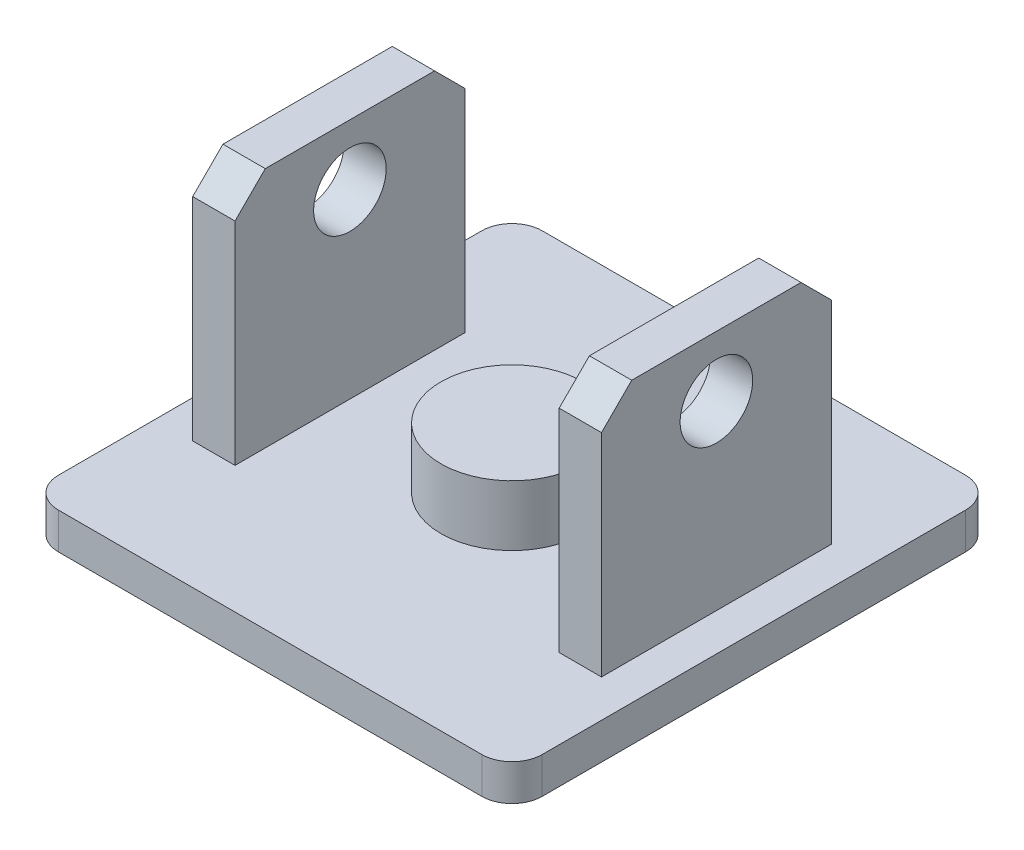
from build123d import *

# Parameters (mm, degrees)
SKETCH1_W           = 40
SKETCH1_H           = 40
BOSS_EXTRUDE1_DEPTH = 3
SKETCH2_R           = 5.875
BOSS_EXTRUDE2_DEPTH = 5
SKETCH3_W           = 3.5
SKETCH3_H           = 19
BOSS_EXTRUDE3_DEPTH = 20
SKETCH4_R           = 3
CUT_EXTRUDE1_DEPTH  = 3.5
FILLET1_R           = 2.5
CHAMFER1_SIZE       = 2.5


with BuildPart() as part:
    # Sketch1 → Boss-Extrude1 (new body)
    with BuildSketch(Plane(origin=(0, 0, 0), x_dir=(1, 0, 0), z_dir=(0, 1, 0))):
        Rectangle(SKETCH1_W, SKETCH1_H)
    extrude(amount=BOSS_EXTRUDE1_DEPTH)

    # Sketch2 → Boss-Extrude2 (add)
    with BuildSketch(Plane(origin=(0, 3, 0), x_dir=(1, 0, 0), z_dir=(0, 1, 0))):
        Circle(SKETCH2_R)
    extrude(amount=BOSS_EXTRUDE2_DEPTH)

    # Sketch3 → Boss-Extrude3 (add)
    with BuildSketch(Plane(origin=(0, 3, 0), x_dir=(1, 0, 0), z_dir=(0, 1, 0))):
        with Locations((15.15, 0)):
            Rectangle(SKETCH3_W, SKETCH3_H)
    boss_extrude3 = extrude(amount=BOSS_EXTRUDE3_DEPTH)

    # Sketch4 → Cut-Extrude1 (cut)
    with BuildSketch(Plane(origin=(16.9, 0, 0), x_dir=(0, 0, -1), z_dir=(1, 0, 0))):
        with Locations((0, 18)):
            Circle(SKETCH4_R)
    cut_extrude1 = extrude(amount=-CUT_EXTRUDE1_DEPTH, mode=Mode.SUBTRACT)

    # Fillet1
    fillet1_edges = [part.edges().sort_by_distance(p)[0] for p in [
        (20, 1.5, 20),
        (-20, 1.5, 20),
        (-20, 1.5, -20),
        (20, 1.5, -20),
    ]]
    fillet(fillet1_edges, radius=FILLET1_R)

    # Mirror1: Boss-Extrude3, Cut-Extrude1 across plane
    add(boss_extrude3.mirror(Plane(origin=(0, 0, 0), x_dir=(0, 0, 1), z_dir=(1, 0, 0))))
    add(cut_extrude1.mirror(Plane(origin=(0, 0, 0), x_dir=(0, 0, 1), z_dir=(1, 0, 0))), mode=Mode.SUBTRACT)

    # Chamfer1
    chamfer1_edges = [part.edges().sort_by_distance(p)[0] for p in [
        (15.15, 23, -9.5),
        (15.15, 23, 9.5),
        (-15.15, 23, 9.5),
        (-15.15, 23, -9.5),
    ]]
    chamfer(chamfer1_edges, length=CHAMFER1_SIZE)


solid = part.part
